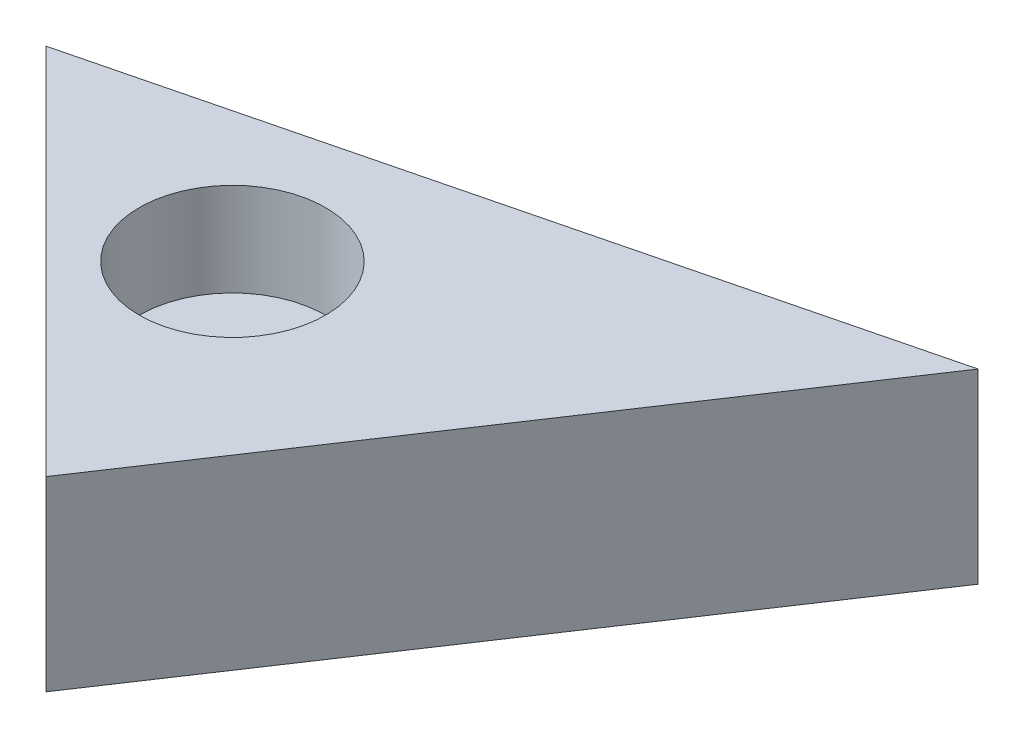
from build123d import *

# Parameters (mm, degrees)
BOSS_EXTRUDE1_DEPTH = 25.4
SKETCH2_R           = 12.7
CUT_EXTRUDE1_DEPTH  = 12.7


with BuildPart() as part:
    # Sketch1 → Boss-Extrude1 (new body)
    with BuildSketch(Plane(origin=(0, 0, 0), x_dir=(1, 0, 0), z_dir=(0, 1, 0))):
        Polygon((0, 0), (50.8, -50.8), (101.6, 25.4), align=None)
    extrude(amount=BOSS_EXTRUDE1_DEPTH)

    # Sketch2 → Cut-Extrude1 (cut)
    with BuildSketch(Plane(origin=(0, 25.4, 0), x_dir=(1, 0, 0), z_dir=(0, 1, 0))):
        with Locations((38.1, -12.7)):
            Circle(SKETCH2_R)
    extrude(amount=-CUT_EXTRUDE1_DEPTH, mode=Mode.SUBTRACT)


solid = part.part
